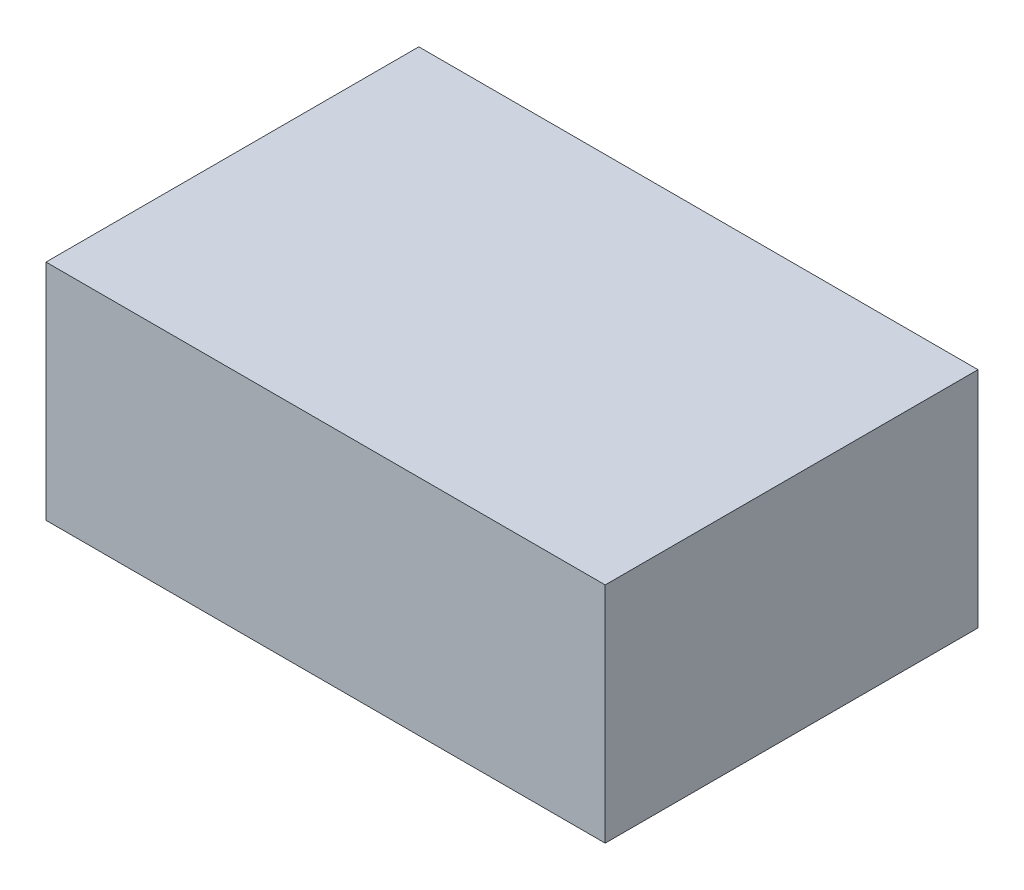
from build123d import *

# Parameters (mm, degrees)
SKETCH1_W           = 300
SKETCH1_H           = 200
BOSS_EXTRUDE1_DEPTH = 120


with BuildPart() as part:
    # Sketch1 → Boss-Extrude1 (new body)
    with BuildSketch(Plane(origin=(0, 0, 0), x_dir=(1, 0, 0), z_dir=(0, 1, 0))):
        Rectangle(SKETCH1_W, SKETCH1_H)
    extrude(amount=BOSS_EXTRUDE1_DEPTH)


solid = part.part
